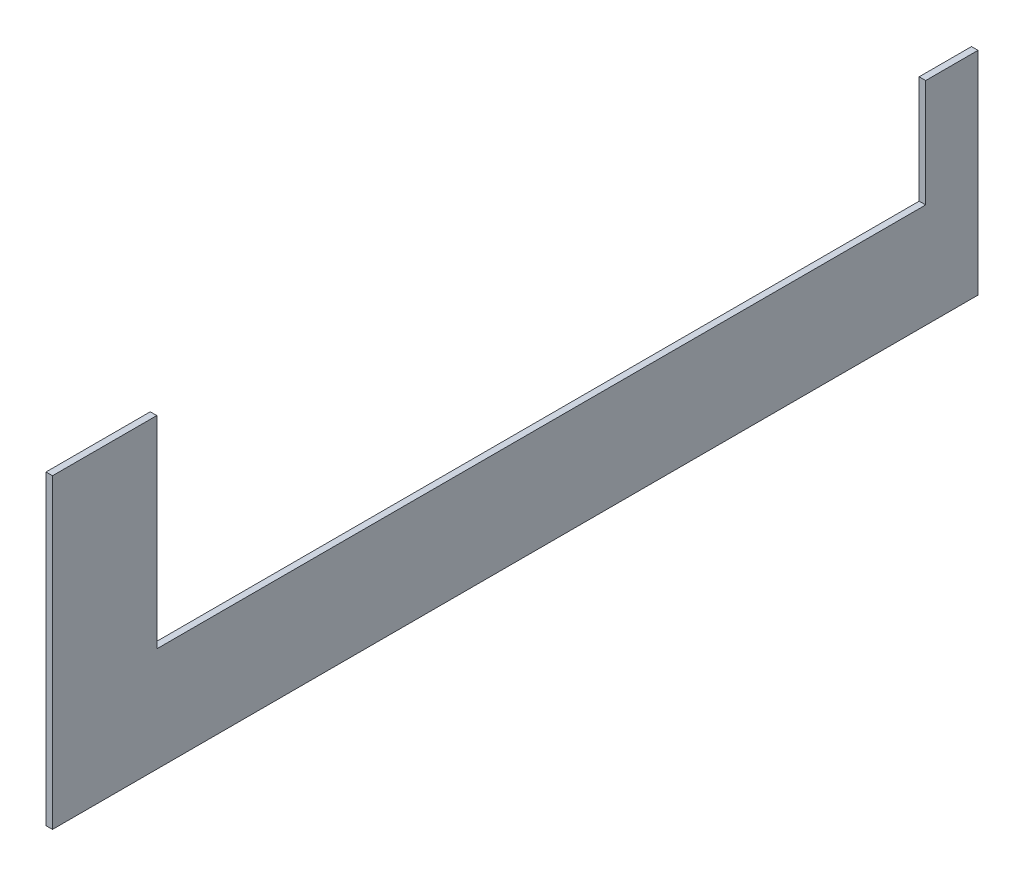
from build123d import *

# Parameters (mm, degrees)
BOSS_EXTRUDE1_DEPTH = 3.175


with BuildPart() as part:
    # Sketch1 → Boss-Extrude1 (new body)
    with BuildSketch(Plane(origin=(0, 0, 0), x_dir=(0, 0, -1), z_dir=(1, 0, 0))):
        Polygon((-225.425, 0), (225.425, 0), (225.425, 103.275983607), (199.926106557, 103.275983607), (199.926106557, 50.8), (-174.625, 50.8), (-174.625, 149.225), (-225.425, 149.225), align=None)
    extrude(amount=BOSS_EXTRUDE1_DEPTH)


solid = part.part
